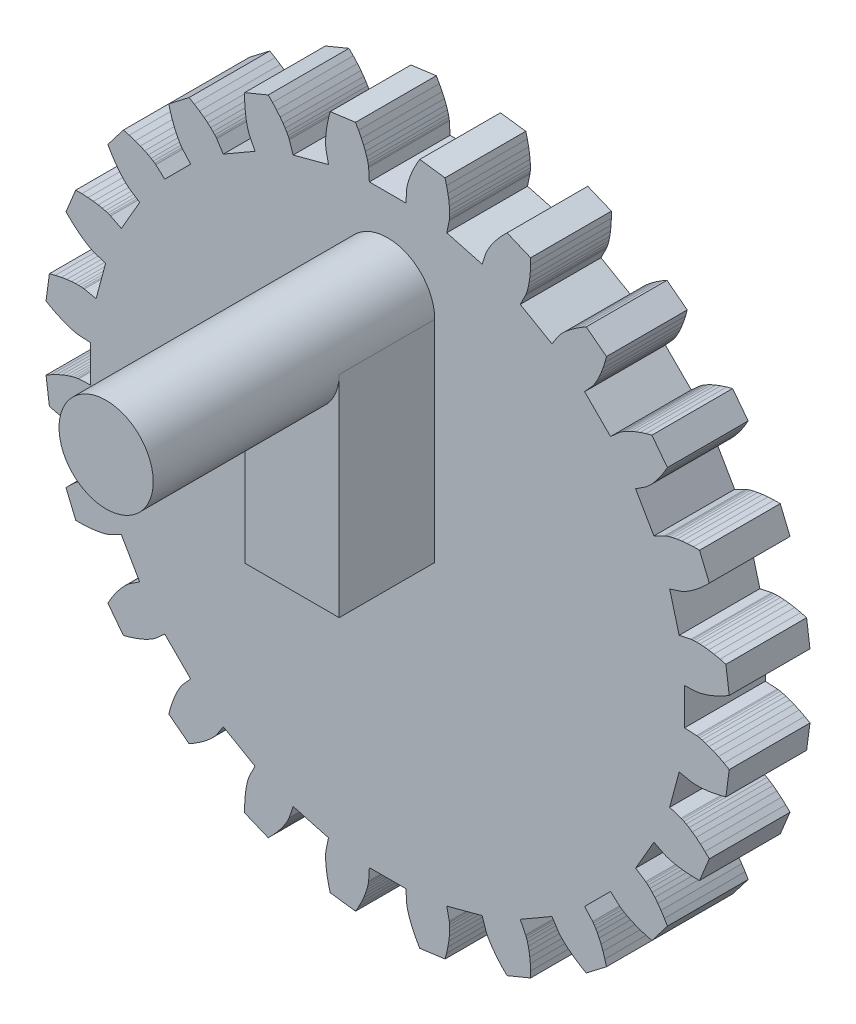
from build123d import *

# Parameters (mm, degrees)
MAIN_GEAR_BODY_DEPTH  = 3
CENTRAL_START         = -3
SKETCH2_R             = 4.825
CENTRAL_FEATURE_DEPTH = 1.3
SKETCH3_OUTSIDE_W     = 34.756
SKETCH3_OUTSIDE_H     = 34.756
TEETH_CLEARANCE_DEPTH = 4
SKETCH7_R             = 1.75
PEG_DEPTH             = 10.46
PEG_SUPPORT_DEPTH     = 3.55


with BuildPart() as part:
    # Model → Main Gear Body (new body)
    with BuildSketch(Plane.XY):
        Polygon((11.481280763, -0.655890262), (11.081931867, -0.633076687), (11.081931867, 0.633076687), (11.481280763, 0.655890262), (11.494959484, 0.657119822), (11.535795525, 0.662587053), (11.603342457, 0.674939875), (11.696960474, 0.69678954), (11.81581907, 0.730698092), (11.958900465, 0.779166001), (12.125003794, 0.844620031), (12.312750022, 0.929401369), (12.520587586, 1.035754071), (12.746798737, 1.165813859), (12.614196933, 2.173024562), (12.36203179, 2.240104916), (12.133750013, 2.289041418), (11.930458058, 2.322341602), (11.753073814, 2.342574636), (11.602323381, 2.352358851), (11.478738615, 2.354349128), (11.382655444, 2.351224158), (11.314212973, 2.345673635), (11.273353363, 2.34038543), (11.259822499, 2.338032781), (10.868176499, 2.256709902), (10.540471892, 3.479720146), (10.920308717, 3.605115467), (10.933203113, 3.609843444), (10.971232676, 3.625693529), (11.033280856, 3.655107871), (11.118053808, 3.700443153), (11.224086216, 3.763959167), (11.349747813, 3.847807762), (11.493250558, 3.954022205), (11.652656464, 4.084506989), (11.82588603, 4.24102813), (12.010727273, 4.425203993), (11.621958453, 5.36377495), (11.361023956, 5.363304455), (11.127854994, 5.351489815), (10.922871322, 5.331039494), (10.746294605, 5.304672682), (10.598148527, 5.275106425), (10.478259688, 5.245042794), (10.386259274, 5.21715615), (10.321585504, 5.194080542), (10.28348684, 5.178397283), (10.27102594, 5.172622753), (9.913772864, 4.99270544), (9.280696176, 6.089226427), (9.615135678, 6.30865801), (9.626367017, 6.316562201), (9.658998451, 6.341714983), (9.711319399, 6.386186306), (9.781470148, 6.45191768), (9.867450435, 6.540712645), (9.967128604, 6.654227783), (10.078251291, 6.7939643), (10.198453625, 6.961260207), (10.325269884, 7.157283131), (10.456144594, 7.383023787), (9.837702711, 8.18899294), (9.585781114, 8.121003659), (9.363615046, 8.049243025), (9.170908956, 7.976435853), (9.007173178, 7.905266052), (8.871727365, 7.838364214), (8.76370468, 7.778295462), (8.682056698, 7.727547573), (8.625559041, 7.688519444), (8.592817683, 7.663509918), (8.582275936, 7.654707033), (8.28376199, 7.388456353), (7.388456353, 8.28376199), (7.654707033, 8.582275936), (7.663509918, 8.592817683), (7.688519444, 8.625559041), (7.727547573, 8.682056698), (7.778295462, 8.76370468), (7.838364214, 8.871727365), (7.905266052, 9.007173178), (7.976435853, 9.170908956), (8.049243025, 9.363615046), (8.121003659, 9.585781114), (8.18899294, 9.837702711), (7.383023787, 10.456144594), (7.157283131, 10.325269884), (6.961260207, 10.198453625), (6.7939643, 10.078251291), (6.654227783, 9.967128604), (6.540712645, 9.867450435), (6.45191768, 9.781470148), (6.386186306, 9.711319399), (6.341714983, 9.658998451), (6.316562201, 9.626367017), (6.30865801, 9.615135678), (6.089226427, 9.280696176), (4.99270544, 9.913772864), (5.172622753, 10.27102594), (5.178397283, 10.28348684), (5.194080542, 10.321585504), (5.21715615, 10.386259274), (5.245042794, 10.478259688), (5.275106425, 10.598148527), (5.304672682, 10.746294605), (5.331039494, 10.922871322), (5.351489815, 11.127854994), (5.363304455, 11.361023956), (5.36377495, 11.621958453), (4.425203993, 12.010727273), (4.24102813, 11.82588603), (4.084506989, 11.652656464), (3.954022205, 11.493250558), (3.847807762, 11.349747813), (3.763959167, 11.224086216), (3.700443153, 11.118053808), (3.655107871, 11.033280856), (3.625693529, 10.971232676), (3.609843444, 10.933203113), (3.605115467, 10.920308717), (3.479720146, 10.540471892), (2.256709902, 10.868176499), (2.338032781, 11.259822499), (2.34038543, 11.273353363), (2.345673635, 11.314212973), (2.351224158, 11.382655444), (2.354349128, 11.478738615), (2.352358851, 11.602323381), (2.342574636, 11.753073814), (2.322341602, 11.930458058), (2.289041418, 12.133750013), (2.240104916, 12.36203179), (2.173024562, 12.614196933), (1.165813859, 12.746798737), (1.035754071, 12.520587586), (0.929401369, 12.312750022), (0.844620031, 12.125003794), (0.779166001, 11.958900465), (0.730698092, 11.81581907), (0.69678954, 11.696960474), (0.674939875, 11.603342457), (0.662587053, 11.535795525), (0.657119822, 11.494959484), (0.655890262, 11.481280763), (0.633076687, 11.081931867), (-0.633076687, 11.081931867), (-0.655890262, 11.481280763), (-0.657119822, 11.494959484), (-0.662587053, 11.535795525), (-0.674939875, 11.603342457), (-0.69678954, 11.696960474), (-0.730698092, 11.81581907), (-0.779166001, 11.958900465), (-0.844620031, 12.125003794), (-0.929401369, 12.312750022), (-1.035754071, 12.520587586), (-1.165813859, 12.746798737), (-2.173024562, 12.614196933), (-2.240104916, 12.36203179), (-2.289041418, 12.133750013), (-2.322341602, 11.930458058), (-2.342574636, 11.753073814), (-2.352358851, 11.602323381), (-2.354349128, 11.478738615), (-2.351224158, 11.382655444), (-2.345673635, 11.314212973), (-2.34038543, 11.273353363), (-2.338032781, 11.259822499), (-2.256709902, 10.868176499), (-3.479720146, 10.540471892), (-3.605115467, 10.920308717), (-3.609843444, 10.933203113), (-3.625693529, 10.971232676), (-3.655107871, 11.033280856), (-3.700443153, 11.118053808), (-3.763959167, 11.224086216), (-3.847807762, 11.349747813), (-3.954022205, 11.493250558), (-4.084506989, 11.652656464), (-4.24102813, 11.82588603), (-4.425203993, 12.010727273), (-5.36377495, 11.621958453), (-5.363304455, 11.361023956), (-5.351489815, 11.127854994), (-5.331039494, 10.922871322), (-5.304672682, 10.746294605), (-5.275106425, 10.598148527), (-5.245042794, 10.478259688), (-5.21715615, 10.386259274), (-5.194080542, 10.321585504), (-5.178397283, 10.28348684), (-5.172622753, 10.27102594), (-4.99270544, 9.913772864), (-6.089226427, 9.280696176), (-6.30865801, 9.615135678), (-6.316562201, 9.626367017), (-6.341714983, 9.658998451), (-6.386186306, 9.711319399), (-6.45191768, 9.781470148), (-6.540712645, 9.867450435), (-6.654227783, 9.967128604), (-6.7939643, 10.078251291), (-6.961260207, 10.198453625), (-7.157283131, 10.325269884), (-7.383023787, 10.456144594), (-8.18899294, 9.837702711), (-8.121003659, 9.585781114), (-8.049243025, 9.363615046), (-7.976435853, 9.170908956), (-7.905266052, 9.007173178), (-7.838364214, 8.871727365), (-7.778295462, 8.76370468), (-7.727547573, 8.682056698), (-7.688519444, 8.625559041), (-7.663509918, 8.592817683), (-7.654707033, 8.582275936), (-7.388456353, 8.28376199), (-8.28376199, 7.388456353), (-8.582275936, 7.654707033), (-8.592817683, 7.663509918), (-8.625559041, 7.688519444), (-8.682056698, 7.727547573), (-8.76370468, 7.778295462), (-8.871727365, 7.838364214), (-9.007173178, 7.905266052), (-9.170908956, 7.976435853), (-9.363615046, 8.049243025), (-9.585781114, 8.121003659), (-9.837702711, 8.18899294), (-10.456144594, 7.383023787), (-10.325269884, 7.157283131), (-10.198453625, 6.961260207), (-10.078251291, 6.7939643), (-9.967128604, 6.654227783), (-9.867450435, 6.540712645), (-9.781470148, 6.45191768), (-9.711319399, 6.386186306), (-9.658998451, 6.341714983), (-9.626367017, 6.316562201), (-9.615135678, 6.30865801), (-9.280696176, 6.089226427), (-9.913772864, 4.99270544), (-10.27102594, 5.172622753), (-10.28348684, 5.178397283), (-10.321585504, 5.194080542), (-10.386259274, 5.21715615), (-10.478259688, 5.245042794), (-10.598148527, 5.275106425), (-10.746294605, 5.304672682), (-10.922871322, 5.331039494), (-11.127854994, 5.351489815), (-11.361023956, 5.363304455), (-11.621958453, 5.36377495), (-12.010727273, 4.425203993), (-11.82588603, 4.24102813), (-11.652656464, 4.084506989), (-11.493250558, 3.954022205), (-11.349747813, 3.847807762), (-11.224086216, 3.763959167), (-11.118053808, 3.700443153), (-11.033280856, 3.655107871), (-10.971232676, 3.625693529), (-10.933203113, 3.609843444), (-10.920308717, 3.605115467), (-10.540471892, 3.479720146), (-10.868176499, 2.256709902), (-11.259822499, 2.338032781), (-11.273353363, 2.34038543), (-11.314212973, 2.345673635), (-11.382655444, 2.351224158), (-11.478738615, 2.354349128), (-11.602323381, 2.352358851), (-11.753073814, 2.342574636), (-11.930458058, 2.322341602), (-12.133750014, 2.289041418), (-12.36203179, 2.240104916), (-12.614196933, 2.173024562), (-12.746798737, 1.165813859), (-12.520587586, 1.035754071), (-12.312750022, 0.929401369), (-12.125003794, 0.844620031), (-11.958900465, 0.779166001), (-11.81581907, 0.730698092), (-11.696960474, 0.69678954), (-11.603342457, 0.674939875), (-11.535795525, 0.662587053), (-11.494959484, 0.657119822), (-11.481280763, 0.655890262), (-11.081931867, 0.633076687), (-11.081931867, -0.633076687), (-11.481280763, -0.655890262), (-11.494959484, -0.657119822), (-11.535795525, -0.662587053), (-11.603342457, -0.674939875), (-11.696960474, -0.69678954), (-11.81581907, -0.730698092), (-11.958900465, -0.779166001), (-12.125003794, -0.844620031), (-12.312750022, -0.929401369), (-12.520587586, -1.035754071), (-12.746798737, -1.165813859), (-12.614196933, -2.173024562), (-12.36203179, -2.240104916), (-12.133750014, -2.289041418), (-11.930458058, -2.322341602), (-11.753073814, -2.342574636), (-11.602323381, -2.352358851), (-11.478738615, -2.354349128), (-11.382655444, -2.351224158), (-11.314212973, -2.345673635), (-11.273353363, -2.34038543), (-11.259822499, -2.338032781), (-10.868176499, -2.256709902), (-10.540471892, -3.479720146), (-10.920308717, -3.605115467), (-10.933203113, -3.609843444), (-10.971232676, -3.625693529), (-11.033280856, -3.655107871), (-11.118053808, -3.700443153), (-11.224086216, -3.763959167), (-11.349747813, -3.847807762), (-11.493250558, -3.954022205), (-11.652656464, -4.084506989), (-11.82588603, -4.24102813), (-12.010727273, -4.425203993), (-11.621958453, -5.36377495), (-11.361023956, -5.363304455), (-11.127854994, -5.351489815), (-10.922871322, -5.331039494), (-10.746294605, -5.304672682), (-10.598148527, -5.275106425), (-10.478259688, -5.245042794), (-10.386259274, -5.21715615), (-10.321585504, -5.194080542), (-10.28348684, -5.178397283), (-10.27102594, -5.172622753), (-9.913772864, -4.99270544), (-9.280696176, -6.089226427), (-9.615135678, -6.30865801), (-9.626367017, -6.316562201), (-9.658998451, -6.341714983), (-9.711319399, -6.386186306), (-9.781470148, -6.45191768), (-9.867450435, -6.540712645), (-9.967128604, -6.654227783), (-10.078251291, -6.7939643), (-10.198453625, -6.961260207), (-10.325269884, -7.157283131), (-10.456144594, -7.383023787), (-9.837702711, -8.18899294), (-9.585781114, -8.121003659), (-9.363615046, -8.049243025), (-9.170908956, -7.976435853), (-9.007173178, -7.905266052), (-8.871727365, -7.838364214), (-8.76370468, -7.778295462), (-8.682056698, -7.727547573), (-8.625559041, -7.688519444), (-8.592817683, -7.663509918), (-8.582275936, -7.654707033), (-8.28376199, -7.388456353), (-7.388456353, -8.28376199), (-7.654707033, -8.582275936), (-7.663509918, -8.592817683), (-7.688519444, -8.625559041), (-7.727547573, -8.682056698), (-7.778295462, -8.76370468), (-7.838364214, -8.871727365), (-7.905266052, -9.007173178), (-7.976435853, -9.170908956), (-8.049243025, -9.363615046), (-8.121003659, -9.585781114), (-8.18899294, -9.837702711), (-7.383023787, -10.456144594), (-7.157283131, -10.325269884), (-6.961260207, -10.198453625), (-6.7939643, -10.078251291), (-6.654227783, -9.967128604), (-6.540712645, -9.867450435), (-6.45191768, -9.781470148), (-6.386186306, -9.711319399), (-6.341714983, -9.658998451), (-6.316562201, -9.626367017), (-6.30865801, -9.615135678), (-6.089226427, -9.280696176), (-4.99270544, -9.913772864), (-5.172622753, -10.27102594), (-5.178397283, -10.28348684), (-5.194080542, -10.321585504), (-5.21715615, -10.386259274), (-5.245042794, -10.478259688), (-5.275106425, -10.598148527), (-5.304672682, -10.746294605), (-5.331039494, -10.922871322), (-5.351489815, -11.127854994), (-5.363304455, -11.361023956), (-5.36377495, -11.621958453), (-4.425203993, -12.010727273), (-4.24102813, -11.82588603), (-4.084506989, -11.652656464), (-3.954022205, -11.493250558), (-3.847807762, -11.349747813), (-3.763959167, -11.224086216), (-3.700443153, -11.118053808), (-3.655107871, -11.033280856), (-3.625693529, -10.971232676), (-3.609843444, -10.933203113), (-3.605115467, -10.920308717), (-3.479720146, -10.540471892), (-2.256709902, -10.868176499), (-2.338032781, -11.259822499), (-2.34038543, -11.273353363), (-2.345673635, -11.314212973), (-2.351224158, -11.382655444), (-2.354349128, -11.478738615), (-2.352358851, -11.602323381), (-2.342574636, -11.753073814), (-2.322341602, -11.930458058), (-2.289041418, -12.133750013), (-2.240104916, -12.36203179), (-2.173024562, -12.614196933), (-1.165813859, -12.746798737), (-1.035754071, -12.520587586), (-0.929401369, -12.312750022), (-0.844620031, -12.125003794), (-0.779166001, -11.958900465), (-0.730698092, -11.81581907), (-0.69678954, -11.696960474), (-0.674939875, -11.603342457), (-0.662587053, -11.535795525), (-0.657119822, -11.494959484), (-0.655890262, -11.481280763), (-0.633076687, -11.081931867), (0.633076687, -11.081931867), (0.655890262, -11.481280763), (0.657119822, -11.494959484), (0.662587053, -11.535795525), (0.674939875, -11.603342457), (0.69678954, -11.696960474), (0.730698092, -11.81581907), (0.779166001, -11.958900465), (0.844620031, -12.125003794), (0.929401369, -12.312750022), (1.035754071, -12.520587586), (1.165813859, -12.746798737), (2.173024562, -12.614196933), (2.240104916, -12.36203179), (2.289041418, -12.133750013), (2.322341602, -11.930458058), (2.342574636, -11.753073814), (2.352358851, -11.602323381), (2.354349128, -11.478738615), (2.351224158, -11.382655444), (2.345673635, -11.314212973), (2.34038543, -11.273353363), (2.338032781, -11.259822499), (2.256709902, -10.868176499), (3.479720146, -10.540471892), (3.605115467, -10.920308717), (3.609843444, -10.933203113), (3.625693529, -10.971232676), (3.655107871, -11.033280856), (3.700443153, -11.118053808), (3.763959167, -11.224086216), (3.847807762, -11.349747813), (3.954022205, -11.493250558), (4.084506989, -11.652656464), (4.24102813, -11.82588603), (4.425203993, -12.010727273), (5.36377495, -11.621958453), (5.363304455, -11.361023956), (5.351489815, -11.127854994), (5.331039494, -10.922871322), (5.304672682, -10.746294605), (5.275106425, -10.598148527), (5.245042794, -10.478259688), (5.21715615, -10.386259274), (5.194080542, -10.321585504), (5.178397283, -10.28348684), (5.172622753, -10.27102594), (4.99270544, -9.913772864), (6.089226427, -9.280696176), (6.30865801, -9.615135678), (6.316562201, -9.626367017), (6.341714983, -9.658998451), (6.386186306, -9.711319399), (6.45191768, -9.781470148), (6.540712645, -9.867450435), (6.654227783, -9.967128604), (6.7939643, -10.078251291), (6.961260207, -10.198453625), (7.157283131, -10.325269884), (7.383023787, -10.456144594), (8.18899294, -9.837702711), (8.121003659, -9.585781114), (8.049243025, -9.363615046), (7.976435853, -9.170908956), (7.905266052, -9.007173178), (7.838364214, -8.871727365), (7.778295462, -8.76370468), (7.727547573, -8.682056698), (7.688519444, -8.625559041), (7.663509918, -8.592817683), (7.654707033, -8.582275936), (7.388456353, -8.28376199), (8.28376199, -7.388456353), (8.582275936, -7.654707033), (8.592817683, -7.663509918), (8.625559041, -7.688519444), (8.682056698, -7.727547573), (8.76370468, -7.778295462), (8.871727365, -7.838364214), (9.007173178, -7.905266052), (9.170908956, -7.976435853), (9.363615046, -8.049243025), (9.585781114, -8.121003659), (9.837702711, -8.18899294), (10.456144594, -7.383023787), (10.325269884, -7.157283131), (10.198453625, -6.961260207), (10.078251291, -6.7939643), (9.967128604, -6.654227783), (9.867450435, -6.540712645), (9.781470148, -6.45191768), (9.711319399, -6.386186306), (9.658998451, -6.341714983), (9.626367017, -6.316562201), (9.615135678, -6.30865801), (9.280696176, -6.089226427), (9.913772864, -4.99270544), (10.27102594, -5.172622753), (10.28348684, -5.178397283), (10.321585504, -5.194080542), (10.386259274, -5.21715615), (10.478259688, -5.245042794), (10.598148527, -5.275106425), (10.746294605, -5.304672682), (10.922871322, -5.331039494), (11.127854994, -5.351489815), (11.361023956, -5.363304455), (11.621958453, -5.36377495), (12.010727273, -4.425203993), (11.82588603, -4.24102813), (11.652656464, -4.084506989), (11.493250558, -3.954022205), (11.349747813, -3.847807762), (11.224086216, -3.763959167), (11.118053808, -3.700443153), (11.033280856, -3.655107871), (10.971232676, -3.625693529), (10.933203113, -3.609843444), (10.920308717, -3.605115467), (10.540471892, -3.479720146), (10.868176499, -2.256709902), (11.259822499, -2.338032781), (11.273353363, -2.34038543), (11.314212973, -2.345673635), (11.382655444, -2.351224158), (11.478738615, -2.354349128), (11.602323381, -2.352358851), (11.753073814, -2.342574636), (11.930458058, -2.322341602), (12.133750013, -2.289041418), (12.36203179, -2.240104916), (12.614196933, -2.173024562), (12.746798737, -1.165813859), (12.520587586, -1.035754071), (12.312750022, -0.929401369), (12.125003794, -0.844620031), (11.958900465, -0.779166001), (11.81581907, -0.730698092), (11.696960474, -0.69678954), (11.603342457, -0.674939875), (11.535795525, -0.662587053), (11.494959484, -0.657119822), align=None)
    extrude(amount=MAIN_GEAR_BODY_DEPTH)

    # Sketch2 → Central Feature (add)
    with BuildSketch(Plane.XY.offset(3).offset(CENTRAL_START)):
        Circle(SKETCH2_R)
    extrude(amount=-CENTRAL_FEATURE_DEPTH)

    # Sketch3 outside → Teeth Clearance (cut, through all)
    with BuildSketch(Plane(origin=(0, 0, 0), x_dir=(-1, 0, 0), z_dir=(0, 0, -1))):
        Rectangle(SKETCH3_OUTSIDE_W, SKETCH3_OUTSIDE_H)
        Polygon((-11.477615752, -0.705762411), (-11.489401209, -0.706821789), (-11.527976246, -0.711986312), (-11.59315705, -0.723906422), (-11.684412493, -0.745204681), (-11.800930862, -0.778445602), (-11.941703887, -0.826131565), (-12.105537815, -0.890691324), (-12.291059816, -0.974468259), (-12.496724072, -1.079708856), (-12.692857237, -1.192475348), (-12.568993946, -2.133310454), (-12.35035774, -2.191471522), (-12.124463053, -2.239896306), (-11.923579494, -2.272801984), (-11.748618777, -2.292758582), (-11.600300442, -2.302384946), (-11.479148956, -2.304336036), (-11.385490572, -2.301289929), (-11.319445598, -2.295933837), (-11.280848297, -2.290938429), (-11.269190232, -2.288911409), (-10.832102983, -2.198152934), (-10.479952826, -3.512395209), (-10.903860726, -3.652339689), (-10.914970416, -3.656413271), (-10.950894363, -3.67138577), (-11.010769034, -3.699769746), (-11.093402628, -3.743960931), (-11.197347347, -3.806226368), (-11.320981611, -3.888722212), (-11.462523738, -3.993485491), (-11.620041165, -4.122424424), (-11.79145931, -4.27730886), (-11.951723284, -4.436995926), (-11.588574488, -5.313714674), (-11.362334938, -5.313306738), (-11.13160417, -5.30161564), (-10.929048936, -5.281407594), (-10.754884713, -5.255401021), (-10.609128716, -5.226311764), (-10.491600388, -5.196840061), (-10.401921726, -5.169657174), (-10.339513439, -5.14738989), (-10.303524216, -5.132574979), (-10.292788022, -5.127599699), (-9.894084181, -4.926807239), (-9.213782319, -6.105124628), (-9.58702561, -6.350016053), (-9.596702427, -6.35682623), (-9.627527127, -6.380586356), (-9.678015304, -6.423499876), (-9.746395706, -6.487572431), (-9.830683114, -6.574619098), (-9.928753148, -6.686302866), (-10.038357612, -6.824130221), (-10.157135911, -6.989444176), (-10.282626082, -7.183417334), (-10.39609914, -7.379142564), (-9.81841283, -8.13199802), (-9.599987788, -8.07304888), (-9.380144858, -8.00203863), (-9.189721754, -7.930094003), (-9.028223029, -7.859896565), (-8.894962401, -7.794074073), (-8.789066591, -7.735188024), (-8.709479105, -7.685720826), (-8.654960526, -7.648059828), (-8.624031987, -7.624435026), (-8.614949317, -7.616850543), (-8.281799893, -7.319707773), (-7.319707773, -8.281799893), (-7.616850543, -8.614949317), (-7.624435026, -8.624031987), (-7.648059828, -8.654960526), (-7.685720826, -8.709479105), (-7.735188024, -8.789066591), (-7.794074073, -8.894962401), (-7.859896565, -9.028223029), (-7.930094003, -9.189721754), (-8.00203863, -9.380144858), (-8.07304888, -9.599987788), (-8.13199802, -9.81841283), (-7.379142564, -10.39609914), (-7.183417334, -10.282626082), (-6.989444176, -10.157135911), (-6.824130221, -10.038357612), (-6.686302866, -9.928753148), (-6.574619098, -9.830683114), (-6.487572431, -9.746395706), (-6.423499876, -9.678015304), (-6.380586356, -9.627527127), (-6.35682623, -9.596702427), (-6.350016053, -9.58702561), (-6.105124628, -9.213782319), (-4.926807239, -9.894084181), (-5.127599699, -10.292788022), (-5.132574979, -10.303524216), (-5.14738989, -10.339513439), (-5.169657174, -10.401921726), (-5.196840061, -10.491600388), (-5.226311764, -10.609128716), (-5.255401021, -10.754884713), (-5.281407594, -10.929048936), (-5.30161564, -11.13160417), (-5.313306738, -11.362334938), (-5.313714674, -11.588574488), (-4.436995926, -11.951723284), (-4.27730886, -11.79145931), (-4.122424424, -11.620041165), (-3.993485491, -11.462523738), (-3.888722212, -11.320981611), (-3.806226368, -11.197347347), (-3.743960931, -11.093402628), (-3.699769746, -11.010769034), (-3.67138577, -10.950894363), (-3.656413271, -10.914970416), (-3.652339689, -10.903860726), (-3.512395209, -10.479952826), (-2.198152934, -10.832102983), (-2.288911409, -11.269190232), (-2.290938429, -11.280848297), (-2.295933837, -11.319445598), (-2.301289929, -11.385490572), (-2.304336036, -11.479148956), (-2.302384946, -11.600300442), (-2.292758582, -11.748618777), (-2.272801984, -11.923579494), (-2.239896306, -12.124463053), (-2.191471522, -12.35035774), (-2.133310454, -12.568993946), (-1.192475348, -12.692857237), (-1.079708856, -12.496724072), (-0.974468259, -12.291059816), (-0.890691324, -12.105537815), (-0.826131565, -11.941703887), (-0.778445602, -11.800930862), (-0.745204681, -11.684412493), (-0.723906422, -11.59315705), (-0.711986312, -11.527976246), (-0.706821789, -11.489401209), (-0.705762411, -11.477615752), (-0.680301862, -11.031931867), (0.680301862, -11.031931867), (0.705762411, -11.477615752), (0.706821789, -11.489401209), (0.711986312, -11.527976246), (0.723906422, -11.59315705), (0.745204681, -11.684412493), (0.778445602, -11.800930862), (0.826131565, -11.941703887), (0.890691324, -12.105537815), (0.974468259, -12.291059816), (1.079708856, -12.496724072), (1.192475348, -12.692857237), (2.133310454, -12.568993946), (2.191471522, -12.35035774), (2.239896306, -12.124463053), (2.272801984, -11.923579494), (2.292758582, -11.748618777), (2.302384946, -11.600300442), (2.304336036, -11.479148956), (2.301289929, -11.385490572), (2.295933837, -11.319445598), (2.290938429, -11.280848297), (2.288911409, -11.269190232), (2.198152934, -10.832102983), (3.512395209, -10.479952826), (3.652339689, -10.903860726), (3.656413271, -10.914970416), (3.67138577, -10.950894363), (3.699769746, -11.010769034), (3.743960931, -11.093402628), (3.806226368, -11.197347347), (3.888722212, -11.320981611), (3.993485491, -11.462523738), (4.122424424, -11.620041165), (4.27730886, -11.79145931), (4.436995926, -11.951723284), (5.313714674, -11.588574488), (5.313306738, -11.362334938), (5.30161564, -11.13160417), (5.281407594, -10.929048936), (5.255401021, -10.754884713), (5.226311764, -10.609128716), (5.196840061, -10.491600388), (5.169657174, -10.401921726), (5.14738989, -10.339513439), (5.132574979, -10.303524216), (5.127599699, -10.292788022), (4.926807239, -9.894084181), (6.105124628, -9.213782319), (6.350016053, -9.58702561), (6.35682623, -9.596702427), (6.380586356, -9.627527127), (6.423499876, -9.678015304), (6.487572431, -9.746395706), (6.574619098, -9.830683114), (6.686302866, -9.928753148), (6.824130221, -10.038357612), (6.989444176, -10.157135911), (7.183417334, -10.282626082), (7.379142564, -10.39609914), (8.13199802, -9.81841283), (8.07304888, -9.599987788), (8.00203863, -9.380144858), (7.930094003, -9.189721754), (7.859896565, -9.028223029), (7.794074073, -8.894962401), (7.735188024, -8.789066591), (7.685720826, -8.709479105), (7.648059828, -8.654960526), (7.624435026, -8.624031987), (7.616850543, -8.614949317), (7.319707773, -8.281799893), (8.281799893, -7.319707773), (8.614949317, -7.616850543), (8.624031987, -7.624435026), (8.654960526, -7.648059828), (8.709479105, -7.685720826), (8.789066591, -7.735188024), (8.894962401, -7.794074073), (9.028223029, -7.859896565), (9.189721754, -7.930094003), (9.380144858, -8.00203863), (9.599987788, -8.07304888), (9.81841283, -8.13199802), (10.39609914, -7.379142564), (10.282626082, -7.183417334), (10.157135911, -6.989444176), (10.038357612, -6.824130221), (9.928753148, -6.686302866), (9.830683114, -6.574619098), (9.746395706, -6.487572431), (9.678015304, -6.423499876), (9.627527127, -6.380586356), (9.596702427, -6.35682623), (9.58702561, -6.350016053), (9.213782319, -6.105124628), (9.894084181, -4.926807239), (10.292788022, -5.127599699), (10.303524216, -5.132574979), (10.339513439, -5.14738989), (10.401921726, -5.169657174), (10.491600388, -5.196840061), (10.609128716, -5.226311764), (10.754884713, -5.255401021), (10.929048936, -5.281407594), (11.13160417, -5.30161564), (11.362334938, -5.313306738), (11.588574488, -5.313714674), (11.951723284, -4.436995926), (11.79145931, -4.27730886), (11.620041165, -4.122424424), (11.462523738, -3.993485491), (11.320981611, -3.888722212), (11.197347347, -3.806226368), (11.093402628, -3.743960931), (11.010769034, -3.699769746), (10.950894363, -3.67138577), (10.914970416, -3.656413271), (10.903860726, -3.652339689), (10.479952826, -3.512395209), (10.832102983, -2.198152934), (11.269190232, -2.288911409), (11.280848297, -2.290938429), (11.319445598, -2.295933837), (11.385490572, -2.301289929), (11.479148956, -2.304336036), (11.600300442, -2.302384946), (11.748618777, -2.292758582), (11.923579494, -2.272801984), (12.124463053, -2.239896306), (12.35035774, -2.191471522), (12.568993946, -2.133310454), (12.692857237, -1.192475348), (12.496724072, -1.079708856), (12.291059816, -0.974468259), (12.105537815, -0.890691324), (11.941703887, -0.826131565), (11.800930862, -0.778445602), (11.684412493, -0.745204681), (11.59315705, -0.723906422), (11.527976246, -0.711986312), (11.489401209, -0.706821789), (11.477615752, -0.705762411), (11.031931867, -0.680301862), (11.031931867, 0.680301862), (11.477615752, 0.705762411), (11.489401209, 0.706821789), (11.527976246, 0.711986312), (11.59315705, 0.723906422), (11.684412493, 0.745204681), (11.800930862, 0.778445602), (11.941703887, 0.826131565), (12.105537815, 0.890691324), (12.291059816, 0.974468259), (12.496724072, 1.079708856), (12.692857237, 1.192475348), (12.568993946, 2.133310454), (12.35035774, 2.191471522), (12.124463053, 2.239896306), (11.923579494, 2.272801984), (11.748618777, 2.292758582), (11.600300442, 2.302384946), (11.479148956, 2.304336036), (11.385490572, 2.301289929), (11.319445598, 2.295933837), (11.280848297, 2.290938429), (11.269190232, 2.288911409), (10.832102983, 2.198152934), (10.479952826, 3.512395209), (10.903860726, 3.652339689), (10.914970416, 3.656413271), (10.950894363, 3.67138577), (11.010769034, 3.699769746), (11.093402628, 3.743960931), (11.197347347, 3.806226368), (11.320981611, 3.888722212), (11.462523738, 3.993485491), (11.620041165, 4.122424424), (11.79145931, 4.27730886), (11.951723284, 4.436995926), (11.588574488, 5.313714674), (11.362334938, 5.313306738), (11.13160417, 5.30161564), (10.929048936, 5.281407594), (10.754884713, 5.255401021), (10.609128716, 5.226311764), (10.491600388, 5.196840061), (10.401921726, 5.169657174), (10.339513439, 5.14738989), (10.303524216, 5.132574979), (10.292788022, 5.127599699), (9.894084181, 4.926807239), (9.213782319, 6.105124628), (9.58702561, 6.350016053), (9.596702427, 6.35682623), (9.627527127, 6.380586356), (9.678015304, 6.423499876), (9.746395706, 6.487572431), (9.830683114, 6.574619098), (9.928753148, 6.686302866), (10.038357612, 6.824130221), (10.157135911, 6.989444176), (10.282626082, 7.183417334), (10.39609914, 7.379142564), (9.81841283, 8.13199802), (9.599987788, 8.07304888), (9.380144858, 8.00203863), (9.189721754, 7.930094003), (9.028223029, 7.859896565), (8.894962401, 7.794074073), (8.789066591, 7.735188024), (8.709479105, 7.685720826), (8.654960526, 7.648059828), (8.624031987, 7.624435026), (8.614949317, 7.616850543), (8.281799893, 7.319707773), (7.319707773, 8.281799893), (7.616850543, 8.614949317), (7.624435026, 8.624031987), (7.648059828, 8.654960526), (7.685720826, 8.709479105), (7.735188024, 8.789066591), (7.794074073, 8.894962401), (7.859896565, 9.028223029), (7.930094003, 9.189721754), (8.00203863, 9.380144858), (8.07304888, 9.599987788), (8.13199802, 9.81841283), (7.379142564, 10.39609914), (7.183417334, 10.282626082), (6.989444176, 10.157135911), (6.824130221, 10.038357612), (6.686302866, 9.928753148), (6.574619098, 9.830683114), (6.487572431, 9.746395706), (6.423499876, 9.678015304), (6.380586356, 9.627527127), (6.35682623, 9.596702427), (6.350016053, 9.58702561), (6.105124628, 9.213782319), (4.926807239, 9.894084181), (5.127599699, 10.292788022), (5.132574979, 10.303524216), (5.14738989, 10.339513439), (5.169657174, 10.401921726), (5.196840061, 10.491600388), (5.226311764, 10.609128716), (5.255401021, 10.754884713), (5.281407594, 10.929048936), (5.30161564, 11.13160417), (5.313306738, 11.362334938), (5.313714674, 11.588574488), (4.436995926, 11.951723284), (4.27730886, 11.79145931), (4.122424424, 11.620041165), (3.993485491, 11.462523738), (3.888722212, 11.320981611), (3.806226368, 11.197347347), (3.743960931, 11.093402628), (3.699769746, 11.010769034), (3.67138577, 10.950894363), (3.656413271, 10.914970416), (3.652339689, 10.903860726), (3.512395209, 10.479952826), (2.198152934, 10.832102983), (2.288911409, 11.269190232), (2.290938429, 11.280848297), (2.295933837, 11.319445598), (2.301289929, 11.385490572), (2.304336036, 11.479148956), (2.302384946, 11.600300442), (2.292758582, 11.748618777), (2.272801984, 11.923579494), (2.239896306, 12.124463053), (2.191471522, 12.35035774), (2.133310454, 12.568993946), (1.192475348, 12.692857237), (1.079708856, 12.496724072), (0.974468259, 12.291059816), (0.890691324, 12.105537815), (0.826131565, 11.941703887), (0.778445602, 11.800930862), (0.745204681, 11.684412493), (0.723906422, 11.59315705), (0.711986312, 11.527976246), (0.706821789, 11.489401209), (0.705762411, 11.477615752), (0.680301862, 11.031931867), (-0.680301862, 11.031931867), (-0.705762411, 11.477615752), (-0.706821789, 11.489401209), (-0.711986312, 11.527976246), (-0.723906422, 11.59315705), (-0.745204681, 11.684412493), (-0.778445602, 11.800930862), (-0.826131565, 11.941703887), (-0.890691324, 12.105537815), (-0.974468259, 12.291059816), (-1.079708856, 12.496724072), (-1.192475348, 12.692857237), (-2.133310454, 12.568993946), (-2.191471522, 12.35035774), (-2.239896306, 12.124463053), (-2.272801984, 11.923579494), (-2.292758582, 11.748618777), (-2.302384946, 11.600300442), (-2.304336036, 11.479148956), (-2.301289929, 11.385490572), (-2.295933837, 11.319445598), (-2.290938429, 11.280848297), (-2.288911409, 11.269190232), (-2.198152934, 10.832102983), (-3.512395209, 10.479952826), (-3.652339689, 10.903860726), (-3.656413271, 10.914970416), (-3.67138577, 10.950894363), (-3.699769746, 11.010769034), (-3.743960931, 11.093402628), (-3.806226368, 11.197347347), (-3.888722212, 11.320981611), (-3.993485491, 11.462523738), (-4.122424424, 11.620041165), (-4.27730886, 11.79145931), (-4.436995926, 11.951723284), (-5.313714674, 11.588574488), (-5.313306738, 11.362334938), (-5.30161564, 11.13160417), (-5.281407594, 10.929048936), (-5.255401021, 10.754884713), (-5.226311764, 10.609128716), (-5.196840061, 10.491600388), (-5.169657174, 10.401921726), (-5.14738989, 10.339513439), (-5.132574979, 10.303524216), (-5.127599699, 10.292788022), (-4.926807239, 9.894084181), (-6.105124628, 9.213782319), (-6.350016053, 9.58702561), (-6.35682623, 9.596702427), (-6.380586356, 9.627527127), (-6.423499876, 9.678015304), (-6.487572431, 9.746395706), (-6.574619098, 9.830683114), (-6.686302866, 9.928753148), (-6.824130221, 10.038357612), (-6.989444176, 10.157135911), (-7.183417334, 10.282626082), (-7.379142564, 10.39609914), (-8.13199802, 9.81841283), (-8.07304888, 9.599987788), (-8.00203863, 9.380144858), (-7.930094003, 9.189721754), (-7.859896565, 9.028223029), (-7.794074073, 8.894962401), (-7.735188024, 8.789066591), (-7.685720826, 8.709479105), (-7.648059828, 8.654960526), (-7.624435026, 8.624031987), (-7.616850543, 8.614949317), (-7.319707773, 8.281799893), (-8.281799893, 7.319707773), (-8.614949317, 7.616850543), (-8.624031987, 7.624435026), (-8.654960526, 7.648059828), (-8.709479105, 7.685720826), (-8.789066591, 7.735188024), (-8.894962401, 7.794074073), (-9.028223029, 7.859896565), (-9.189721754, 7.930094003), (-9.380144858, 8.00203863), (-9.599987788, 8.07304888), (-9.81841283, 8.13199802), (-10.39609914, 7.379142564), (-10.282626082, 7.183417334), (-10.157135911, 6.989444176), (-10.038357612, 6.824130221), (-9.928753148, 6.686302866), (-9.830683114, 6.574619098), (-9.746395706, 6.487572431), (-9.678015304, 6.423499876), (-9.627527127, 6.380586356), (-9.596702427, 6.35682623), (-9.58702561, 6.350016053), (-9.213782319, 6.105124628), (-9.894084181, 4.926807239), (-10.292788022, 5.127599699), (-10.303524216, 5.132574979), (-10.339513439, 5.14738989), (-10.401921726, 5.169657174), (-10.491600388, 5.196840061), (-10.609128716, 5.226311764), (-10.754884713, 5.255401021), (-10.929048936, 5.281407594), (-11.13160417, 5.30161564), (-11.362334938, 5.313306738), (-11.588574488, 5.313714674), (-11.951723284, 4.436995926), (-11.79145931, 4.27730886), (-11.620041165, 4.122424424), (-11.462523738, 3.993485491), (-11.320981611, 3.888722212), (-11.197347347, 3.806226368), (-11.093402628, 3.743960931), (-11.010769034, 3.699769746), (-10.950894363, 3.67138577), (-10.914970416, 3.656413271), (-10.903860726, 3.652339689), (-10.479952826, 3.512395209), (-10.832102983, 2.198152934), (-11.269190232, 2.288911409), (-11.280848297, 2.290938429), (-11.319445598, 2.295933837), (-11.385490572, 2.301289929), (-11.479148956, 2.304336036), (-11.600300442, 2.302384946), (-11.748618777, 2.292758582), (-11.923579494, 2.272801984), (-12.124463053, 2.239896306), (-12.35035774, 2.191471522), (-12.568993946, 2.133310454), (-12.692857237, 1.192475348), (-12.496724072, 1.079708856), (-12.291059816, 0.974468259), (-12.105537815, 0.890691324), (-11.941703887, 0.826131565), (-11.800930862, 0.778445602), (-11.684412493, 0.745204681), (-11.59315705, 0.723906422), (-11.527976246, 0.711986312), (-11.489401209, 0.706821789), (-11.477615752, 0.705762411), (-11.031931867, 0.680301862), (-11.031931867, -0.680301862), align=None, mode=Mode.SUBTRACT)
    extrude(amount=-TEETH_CLEARANCE_DEPTH, mode=Mode.SUBTRACT)

    # Sketch7 → peg (add)
    with BuildSketch(Plane.XY.offset(3)):
        with Locations((0, 7.825)):
            Circle(SKETCH7_R)
    extrude(amount=PEG_DEPTH)

    # Sketch8 → peg support (add)
    with BuildSketch(Plane.XY.offset(3)):
        with BuildLine():
            Line((-1.75, 7.825), (-1.75, 0))
            Line((-1.75, 0), (1.75, 0))
            Line((1.75, 0), (1.75, 7.825))
            ThreePointArc((1.75, 7.825), (0, 6.075), (-1.75, 7.825))
        make_face()
    extrude(amount=PEG_SUPPORT_DEPTH)


solid = part.part
